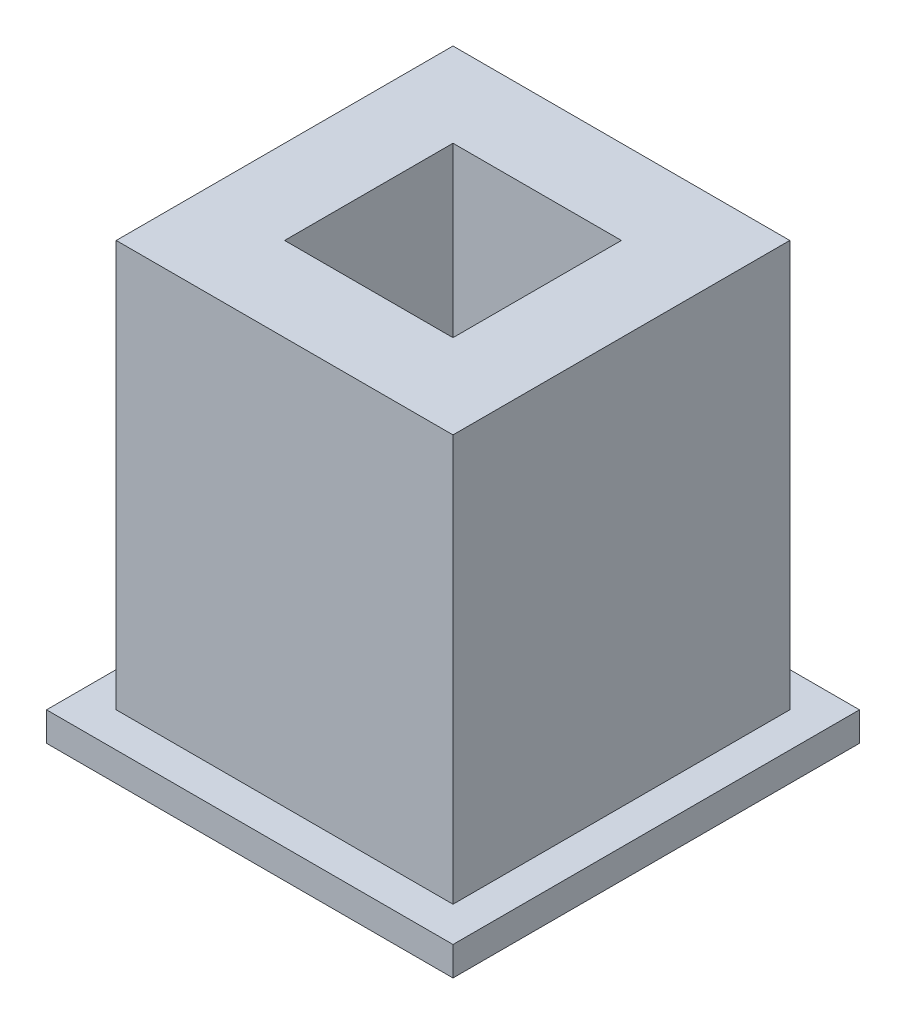
from build123d import *

# Parameters (mm, degrees)
SKETCH1_W           = 5.8
SKETCH1_H           = 5.8
BOSS_EXTRUDE1_DEPTH = 7
SKETCH3_W           = 2.9
SKETCH3_H           = 2.9
CUT_EXTRUDE1_DEPTH  = 3.8
SKETCH4_W           = 7
SKETCH4_H           = 7
BOSS_EXTRUDE2_DEPTH = 1.7
CHAMFER1_SIZE       = 1.2


with BuildPart() as part:
    # Sketch1 → Boss-Extrude1 (new body)
    with BuildSketch(Plane(origin=(0, 0, 0), x_dir=(1, 0, 0), z_dir=(0, 1, 0))):
        with Locations((2.9, 2.9)):
            Rectangle(SKETCH1_W, SKETCH1_H)
    extrude(amount=BOSS_EXTRUDE1_DEPTH)

    # Sketch3 → Cut-Extrude1 (cut)
    with BuildSketch(Plane(origin=(0, 7, 0), x_dir=(1, 0, 0), z_dir=(0, 1, 0))):
        with Locations((2.9, 2.9)):
            Rectangle(SKETCH3_W, SKETCH3_H)
    extrude(amount=-CUT_EXTRUDE1_DEPTH, mode=Mode.SUBTRACT)

    # Sketch4 → Boss-Extrude2 (add)
    with BuildSketch(Plane.XZ):
        with Locations((2.9, -2.9)):
            Rectangle(SKETCH4_W, SKETCH4_H)
    extrude(amount=BOSS_EXTRUDE2_DEPTH)

    # Chamfer1
    chamfer1_edges = [part.edges().sort_by_distance(p)[0] for p in [
        (-0.6, -1.7, -2.9),
        (2.9, -1.7, -6.4),
        (6.4, -1.7, -2.9),
        (2.9, -1.7, 0.6),
    ]]
    chamfer(chamfer1_edges, length=CHAMFER1_SIZE)


solid = part.part
